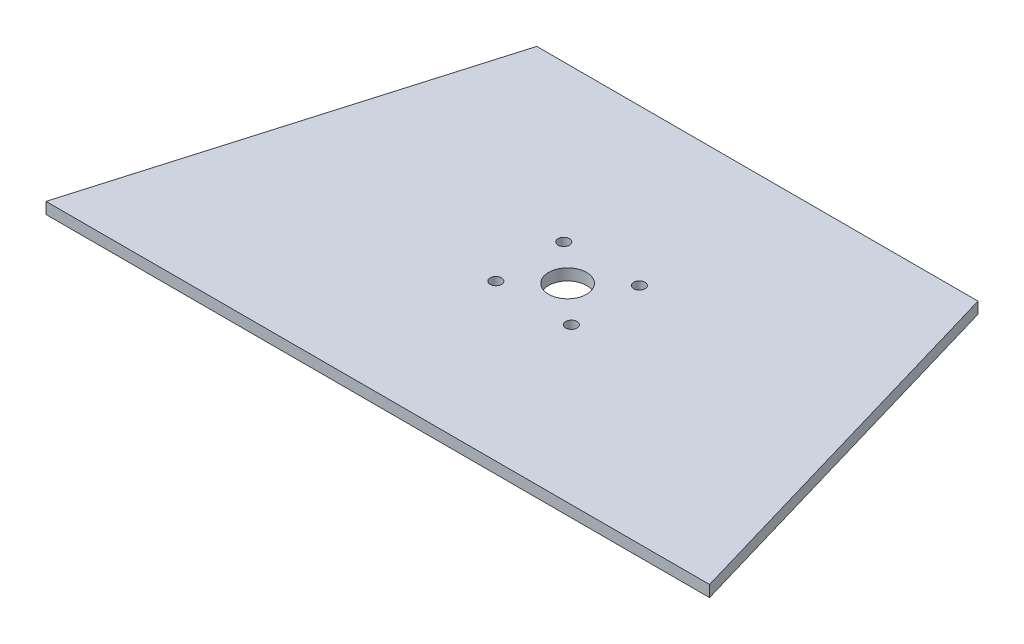
from build123d import *

# Parameters (mm, degrees)
BOSS_EXTRUDE1_DEPTH        = 3
F_3_0MM_DOWEL_HOLE1_D      = 3
F_3_0MM_DOWEL_HOLE1_DEPTH  = 3
F_10_0MM_DOWEL_HOLE1_D     = 10
F_10_0MM_DOWEL_HOLE1_DEPTH = 3


with BuildPart() as part:
    # Sketch1 → Boss-Extrude1 (new body)
    with BuildSketch(Plane(origin=(0, 0, 0), x_dir=(1, 0, 0), z_dir=(0, 1, 0))):
        Polygon((5.2, 0), (180, 0), (150.720058283, 100), (34.479941717, 100), align=None)
    extrude(amount=BOSS_EXTRUDE1_DEPTH)

    # Ø3.0mm Dowel Hole1
    with Locations(Plane(origin=(0, 0, 0), x_dir=(-1, 0, 0), z_dir=(0, -1, 0))):
        with Locations((-82.65, 58.95), (-82.65, 41.05), (-102.55, 41.05), (-102.55, 58.95)):
            Hole(F_3_0MM_DOWEL_HOLE1_D / 2, depth=F_3_0MM_DOWEL_HOLE1_DEPTH)

    # Ø10.0mm Dowel Hole1
    with Locations(Plane(origin=(0, 3, 0), x_dir=(1, 0, 0), z_dir=(0, 1, 0))):
        with Locations((92.6, 50)):
            Hole(F_10_0MM_DOWEL_HOLE1_D / 2, depth=F_10_0MM_DOWEL_HOLE1_DEPTH)


solid = part.part
